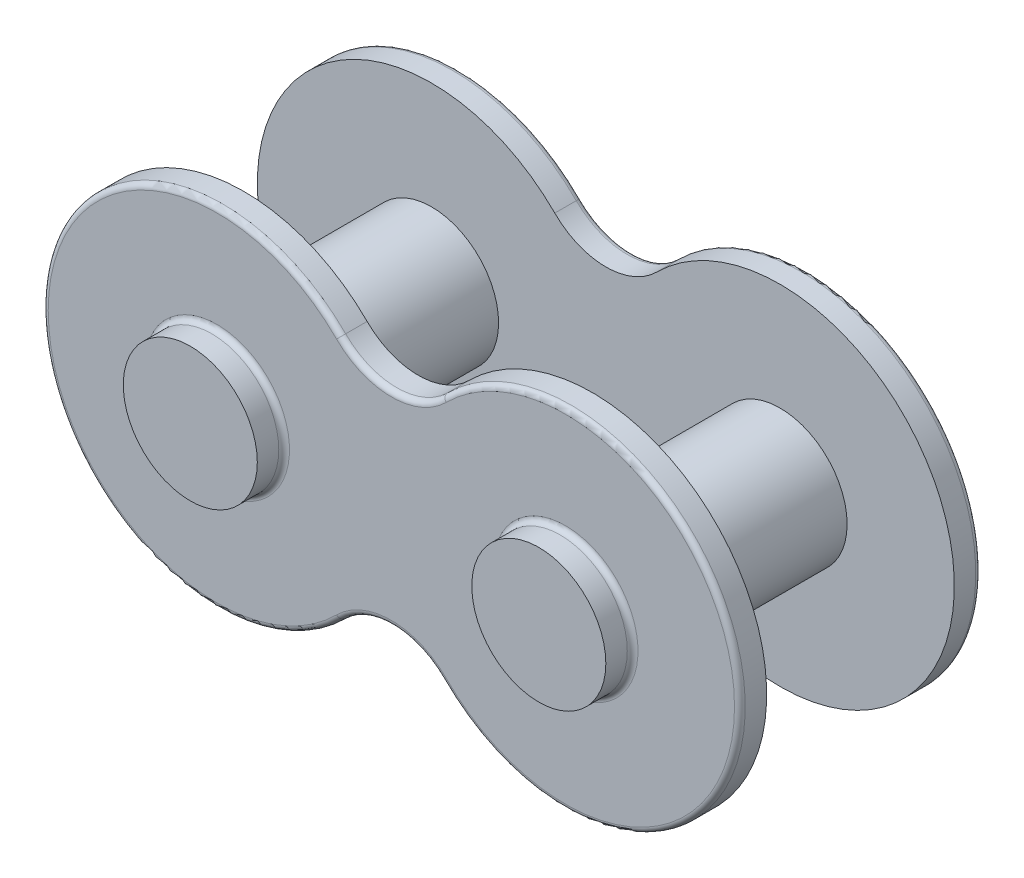
from build123d import *

# Parameters (mm, degrees)
CROQUIS1_R                   = 2.5
SALIENTE_EXTRUIR1_DEPTH      = 1
CROQUIS2_R                   = 2.5
SALIENTE_EXTRUIR2_DEPTH      = 10
SALIENTE_EXTRUIR2_DEPTH_BACK = 1
REDONDEO1_R                  = 0.2


with BuildPart() as part:
    # Croquis1 → Saliente-Extruir1 (new body)
    with BuildSketch(Plane.XY):
        with BuildLine():
            ThreePointArc((-1.903805922, 4.596194078), (-13, 0), (-1.903805922, -4.596194078))
            ThreePointArc((-1.903805922, -4.596194078), (0, -3.807611845), (1.903805922, -4.596194078))
            ThreePointArc((1.903805922, -4.596194078), (13, 0), (1.903805922, 4.596194078))
            ThreePointArc((1.903805922, 4.596194078), (0, 3.807611845), (-1.903805922, 4.596194078))
        make_face()
        with Locations((-6.5, 0)):
            Circle(CROQUIS1_R, mode=Mode.SUBTRACT)
        with Locations((6.5, 0)):
            Circle(CROQUIS1_R, mode=Mode.SUBTRACT)
    saliente_extruir1 = extrude(amount=SALIENTE_EXTRUIR1_DEPTH)

    # Croquis2 → Saliente-Extruir2 (add, two sides)
    with BuildSketch(Plane.XY) as saliente_extruir2_sk:
        with Locations((-6.5, 0)):
            Circle(CROQUIS2_R)
        with Locations((6.5, 0)):
            Circle(CROQUIS2_R)
    extrude(amount=SALIENTE_EXTRUIR2_DEPTH)
    extrude(saliente_extruir2_sk.sketch, amount=-SALIENTE_EXTRUIR2_DEPTH_BACK)

    # Simetría1: Saliente-Extruir1 across plane
    add(saliente_extruir1.mirror(Plane(origin=(0, 0, 4.5), x_dir=(1, 0, 0), z_dir=(0, 0, -1))))

    # Redondeo1
    redondeo1_edges = [part.edges().sort_by_distance(p)[0] for p in [
        (-9, 0, 0),
        (4, 0, 0),
        (0, -3.807611845, 9),
        (13, 0, 9),
        (0, 3.807611845, 9),
        (-13, 0, 9),
        (-9, 0, 9),
        (4, 0, 9),
        (-13, 0, 0),
        (0, 3.807611845, 0),
        (13, 0, 0),
        (0, -3.807611845, 0),
    ]]
    fillet(redondeo1_edges, radius=REDONDEO1_R)


solid = part.part
